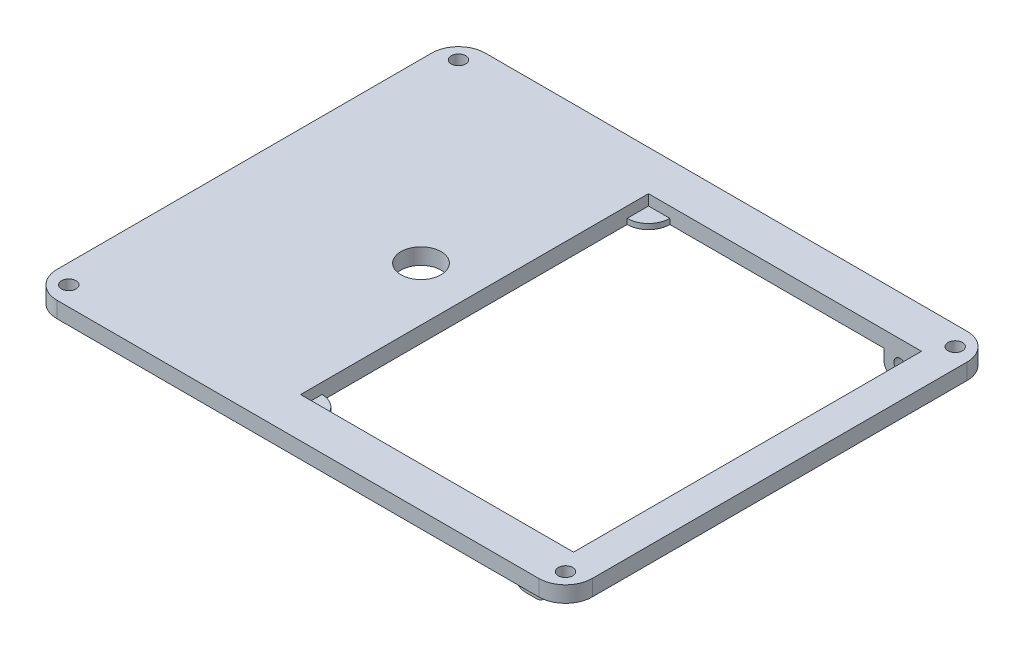
from build123d import *

# Parameters (mm, degrees)
SKETCH_1_R             = 1.35
SKETCH_1_W             = 51
SKETCH_1_H             = 65
EXTRUDE_1_DEPTH        = 3
SKETCH_2_W             = 6
SKETCH_2_H             = 4
EXTRUDE_2_DEPTH        = 4
SKETCH_4_R             = 1.15
CUT_EXTRUDE_2_DEPTH    = 4
FILLET_2_R             = 2
FILLET_2_OF_MIRROR_1_R = 2
SKETCH_5_R             = 3.75
CUT_EXTRUDE_3_DEPTH    = 3
EXTRUDE_3_DEPTH        = 1
SKETCH_7_R             = 1.15
EXTRUDE_4_DEPTH        = 2


with BuildPart() as part:
    # 草图1 → 凸台-拉伸1 (new body)
    with BuildSketch(Plane(origin=(0, 0, 0), x_dir=(1, 0, 0), z_dir=(0, 1, 0))):
        with BuildLine():
            Line((-45, 40), (45, 40))
            ThreePointArc((45, 40), (48.535533906, 38.535533906), (50, 35))
            Line((50, 35), (50, -35))
            ThreePointArc((50, -35), (48.535533906, -38.535533906), (45, -40))
            Line((45, -40), (-45, -40))
            ThreePointArc((-45, -40), (-48.535533906, -38.535533906), (-50, -35))
            Line((-50, -35), (-50, 35))
            ThreePointArc((-50, 35), (-48.535533906, 38.535533906), (-45, 40))
        make_face()
        with Locations((-46.4, 36.4)):
            Circle(SKETCH_1_R, mode=Mode.SUBTRACT)
        with Locations((46.4, 36.4)):
            Circle(SKETCH_1_R, mode=Mode.SUBTRACT)
        with Locations((46.4, -36.4)):
            Circle(SKETCH_1_R, mode=Mode.SUBTRACT)
        with Locations((-46.4, -36.4)):
            Circle(SKETCH_1_R, mode=Mode.SUBTRACT)
        with Locations((18.5, 0)):
            Rectangle(SKETCH_1_W, SKETCH_1_H, mode=Mode.SUBTRACT)
    extrude(amount=EXTRUDE_1_DEPTH)

    # 草图2 → 凸台-拉伸2 (add)
    with BuildSketch(Plane(origin=(0, 0, 0), x_dir=(-1, 0, 0), z_dir=(0, -1, 0))):
        with Locations((-40, 34.5)):
            Rectangle(SKETCH_2_W, SKETCH_2_H)
    extrude_2 = extrude(amount=EXTRUDE_2_DEPTH)

    # 草图4 → 切除-拉伸2 (cut)
    with BuildSketch(Plane.XY.offset(-32.5)):
        with Locations((40, -1.3)):
            Circle(SKETCH_4_R)
    cut_extrude_2 = extrude(amount=-CUT_EXTRUDE_2_DEPTH, mode=Mode.SUBTRACT)

    # 圆角2
    fillet_2_edges = [part.edges().sort_by_distance(p)[0] for p in [
        (43, -4, -34.5),
        (37, -4, -34.5),
    ]]
    fillet(fillet_2_edges, radius=FILLET_2_R)

    # 镜向1: 凸台-拉伸2, 切除-拉伸2 across plane
    add(extrude_2.mirror(Plane.XY))
    add(cut_extrude_2.mirror(Plane.XY), mode=Mode.SUBTRACT)

    # 圆角2 of 镜向1
    fillet_2_of_mirror_1_edges = [part.edges().sort_by_distance(p)[0] for p in [
        (43, -4, 34.5),
        (37, -4, 34.5),
    ]]
    fillet(fillet_2_of_mirror_1_edges, radius=FILLET_2_OF_MIRROR_1_R)

    # 草图5 → 切除-拉伸3 (cut)
    with BuildSketch(Plane(origin=(0, 3, 0), x_dir=(1, 0, 0), z_dir=(0, 1, 0))):
        with Locations((-17, 0)):
            Circle(SKETCH_5_R)
    extrude(amount=-CUT_EXTRUDE_3_DEPTH, mode=Mode.SUBTRACT)

    # 草图6 → 凸台-拉伸3 (add)
    with BuildSketch(Plane.XZ):
        with BuildLine():
            Line((-7, -28.5), (-7, -32.5))
            Line((-7, -32.5), (-3, -32.5))
            ThreePointArc((-3, -32.5), (-4.171572875, -29.671572875), (-7, -28.5))
        make_face()
        with BuildLine():
            Line((-7, 28.5), (-7, 32.5))
            Line((-7, 32.5), (-3, 32.5))
            ThreePointArc((-3, 32.5), (-4.171572875, 29.671572875), (-7, 28.5))
        make_face()
    extrude(amount=-EXTRUDE_3_DEPTH)

    # 草图7 → 凸台-拉伸4 (add)
    with BuildSketch(Plane.XY.offset(36.5)):
        with Locations((40, -1.3)):
            Circle(SKETCH_7_R)
    extrude(amount=-EXTRUDE_4_DEPTH)


solid = part.part
